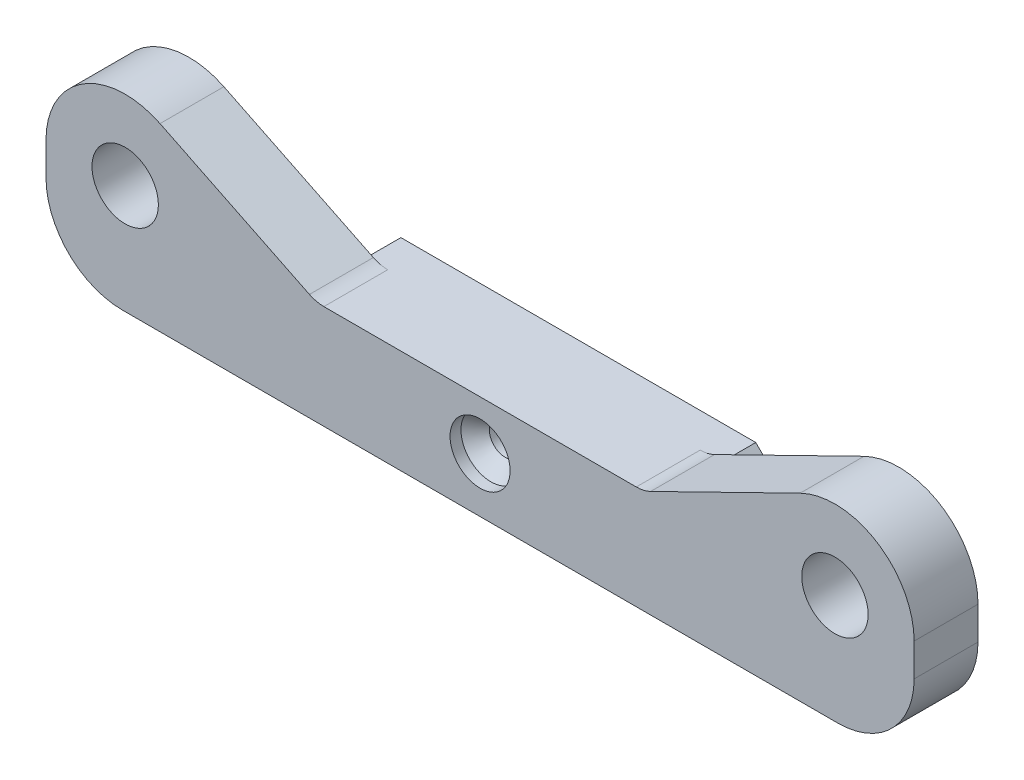
from build123d import *

# Parameters (mm, degrees)
SKETCH1_W                    = 77.5
SKETCH1_H                    = 7
BOSS_EXTRUDE1_DEPTH          = 9
BOSS_EXTRUDE1_DEPTH_BACK     = 9
SKETCH2_W                    = 20
SKETCH2_H                    = 6.3
CUT_EXTRUDE1_DEPTH           = 8
SKETCH3_W                    = 12.5
SKETCH3_H                    = 5.85
BOSS_EXTRUDE2_DEPTH          = 8
SKETCH4_R                    = 3.04
CUT_EXTRUDE2_DEPTH           = 22
CUT_EXTRUDE2_DEPTH_BACK      = 24.5
CUT_EXTRUDE3_DEPTH           = 5
SKETCH6_R                    = 6.2
CUT_EXTRUDE4_DEPTH           = 1
MIRROR2_COPY_1_SKETCH_R      = 6.2
MIRROR2_COPY_1_DEPTH         = 1
SKETCH7_W                    = 12.5
SKETCH7_H                    = 8.5
CUT_EXTRUDE5_DEPTH           = 1
MIRROR5_COPY_1_SKETCH_W      = 12.5
MIRROR5_COPY_1_SKETCH_H      = 8.5
MIRROR5_COPY_1_DEPTH         = 1
TAP_DRILL_FOR_M2_TAP1_D      = 1.6
CUT_EXTRUDE6_DEPTH           = 27
SKETCH12_W                   = 83.830839912
SKETCH12_H                   = 36.587504352
CUT_EXTRUDE7_DEPTH           = 22
F_2_0_2_DIAMETER_HOLE1_D     = 2
F_2_0_2_DIAMETER_HOLE1_DEPTH = 30.5
F_2_0_2_DIAMETER_HOLE2_D     = 2
F_2_0_2_DIAMETER_HOLE2_DEPTH = 16
F_2_0_2_DIAMETER_HOLE2_TIP   = 0.600860619
ESQUISSE2_R                  = 3.04
BOSS_EXTRU_1_DEPTH           = 1
ESQUISSE5_R                  = 0.8
BOSS_EXTRU_3_DEPTH           = 5.85
ESQUISSE6_R                  = 0.8
BOSS_EXTRU_4_DEPTH           = 9
BOSS_EXTRUDE3_DEPTH          = 1.5
BOSS_EXTRUDE4_DEPTH          = 1
SKETCH28_R                   = 7.25
SKETCH28_R_2                 = 6.25
BOSS_EXTRUDE7_DEPTH          = 5.85
BOSS_EXTRUDE5_DEPTH          = 5.85
FILLET2_R                    = 3
CHAMFER1_SIZE                = 2.5
SKETCH27_R                   = 1
BOSS_EXTRUDE6_DEPTH          = 2
BOSS_EXTRUDE8_DEPTH          = 5.85
FILLET3_R                    = 7


with BuildPart() as part:
    # Sketch1 → Boss-Extrude1 (new body, two sides)
    with BuildSketch(Plane.XY) as boss_extrude1_sk:
        Rectangle(SKETCH1_W, SKETCH1_H)
    extrude(amount=BOSS_EXTRUDE1_DEPTH)
    extrude(boss_extrude1_sk.sketch, amount=-BOSS_EXTRUDE1_DEPTH_BACK)

    # Sketch2 → Cut-Extrude1 (cut, through all)
    with BuildSketch(Plane(origin=(0, 3.5, 0), x_dir=(1, 0, 0), z_dir=(0, 1, 0))):
        with Locations((-28.75, 0)):
            Rectangle(SKETCH2_W, SKETCH2_H)
        with Locations((28.75, 0)):
            Rectangle(SKETCH2_W, SKETCH2_H)
    extrude(amount=-CUT_EXTRUDE1_DEPTH, mode=Mode.SUBTRACT)

    # Sketch3 → Boss-Extrude2 (add)
    with BuildSketch(Plane(origin=(0, 3.5, 0), x_dir=(1, 0, 0), z_dir=(0, 1, 0))):
        with Locations((-32.5, 6.075)):
            Rectangle(SKETCH3_W, SKETCH3_H)
        with Locations((-32.5, -6.075)):
            Rectangle(SKETCH3_W, SKETCH3_H)
        with Locations((32.5, -6.075)):
            Rectangle(SKETCH3_W, SKETCH3_H)
        with Locations((32.5, 6.075)):
            Rectangle(SKETCH3_W, SKETCH3_H)
    extrude(amount=BOSS_EXTRUDE2_DEPTH)

    # Sketch4 → Cut-Extrude2 (cut, two sides)
    with BuildSketch(Plane.XY) as cut_extrude2_sk:
        with Locations((-32.5, 5)):
            Circle(SKETCH4_R)
        with Locations((32.5, 5)):
            Circle(SKETCH4_R)
    extrude(amount=CUT_EXTRUDE2_DEPTH, mode=Mode.SUBTRACT)
    extrude(cut_extrude2_sk.sketch, amount=-CUT_EXTRUDE2_DEPTH_BACK, mode=Mode.SUBTRACT)

    # Sketch5 → Cut-Extrude3 (cut)
    with BuildSketch(Plane.XY):
        Polygon((15, 3.5), (36.256888292, -2.195766051), (36.256888292, 11.5), (15, 11.5), align=None)
    extrude(amount=-CUT_EXTRUDE3_DEPTH, mode=Mode.SUBTRACT)

    # Sketch6 → Cut-Extrude4 (cut)
    with BuildSketch(Plane.XY.offset(9)):
        with Locations((32.5, 5)):
            Circle(SKETCH6_R)
    cut_extrude4 = extrude(amount=-CUT_EXTRUDE4_DEPTH, mode=Mode.SUBTRACT)

    # Mirror1: Cut-Extrude4 across plane
    add(cut_extrude4.mirror(Plane.XY), mode=Mode.SUBTRACT)

    # Mirror2: Cut-Extrude4 across plane
    add(cut_extrude4.mirror(Plane(origin=(0, 0, 0), x_dir=(0, 0, 1), z_dir=(1, 0, 0))), mode=Mode.SUBTRACT)

    # Mirror2 copy 1 sketch → Mirror2 copy 1 (cut)
    with BuildSketch(Plane(origin=(0, 0, -9), x_dir=(-1, 0, 0), z_dir=(0, 0, -1))):
        with Locations((32.5, 5)):
            Circle(MIRROR2_COPY_1_SKETCH_R)
    extrude(amount=-MIRROR2_COPY_1_DEPTH, mode=Mode.SUBTRACT)

    # Sketch7 → Cut-Extrude5 (cut)
    with BuildSketch(Plane.XY.offset(9)):
        with Locations((-32.5, 7.25)):
            Rectangle(SKETCH7_W, SKETCH7_H)
    cut_extrude5 = extrude(amount=-CUT_EXTRUDE5_DEPTH, mode=Mode.SUBTRACT)

    # Mirror3: Cut-Extrude5 across plane
    add(cut_extrude5.mirror(Plane(origin=(0, 0, 0), x_dir=(0, 0, 1), z_dir=(1, 0, 0))), mode=Mode.SUBTRACT)

    # Mirror5: Cut-Extrude5 across plane
    add(cut_extrude5.mirror(Plane.XY), mode=Mode.SUBTRACT)

    # Mirror5 copy 1 sketch → Mirror5 copy 1 (cut)
    with BuildSketch(Plane(origin=(0, 0, -9), x_dir=(-1, 0, 0), z_dir=(0, 0, -1))):
        with Locations((-32.5, 7.25)):
            Rectangle(MIRROR5_COPY_1_SKETCH_W, MIRROR5_COPY_1_SKETCH_H)
    extrude(amount=-MIRROR5_COPY_1_DEPTH, mode=Mode.SUBTRACT)

    # Tap Drill for M2 Tap1 (through all)
    with Locations(Plane.XY.offset(9)):
        with Locations((-25, 0), (0, 0), (25, 0)):
            Hole(TAP_DRILL_FOR_M2_TAP1_D / 2)

    # Sketch11 → Cut-Extrude6 (cut)
    with BuildSketch(Plane.XY.offset(9)):
        with BuildLine():
            Line((-38.75, 4.999999534), (-38.75, 21.221242017))
            Line((-38.75, 21.221242017), (-26.25, 21.221242017))
            Line((-26.25, 21.221242017), (-26.25, 4.999999534))
            ThreePointArc((-26.25, 4.999999534), (-32.5, 11.25), (-38.75, 4.999999534))
        make_face()
    cut_extrude6 = extrude(amount=-CUT_EXTRUDE6_DEPTH, mode=Mode.SUBTRACT)

    # Mirror6: Cut-Extrude6 across plane
    add(cut_extrude6.mirror(Plane(origin=(0, 0, 0), x_dir=(0, 0, 1), z_dir=(1, 0, 0))), mode=Mode.SUBTRACT)

    # Sketch12 → Cut-Extrude7 (cut)
    with BuildSketch(Plane.XY):
        Rectangle(SKETCH12_W, SKETCH12_H)
    extrude(amount=-CUT_EXTRUDE7_DEPTH, mode=Mode.SUBTRACT)

    # 2.0 _2_ Diameter Hole1
    with Locations(Plane.XY.offset(9)):
        with Locations((-15, 0)):
            Hole(F_2_0_2_DIAMETER_HOLE1_D / 2, depth=F_2_0_2_DIAMETER_HOLE1_DEPTH)

    # 2.0 _2_ Diameter Hole2
    with Locations(Plane.XY.offset(9)):
        with Locations((15, 0)):
            Hole(F_2_0_2_DIAMETER_HOLE2_D / 2, depth=F_2_0_2_DIAMETER_HOLE2_DEPTH)
            with Locations((0, 0, -(F_2_0_2_DIAMETER_HOLE2_DEPTH + F_2_0_2_DIAMETER_HOLE2_TIP / 2))):  # 118° drill point
                Cone(0, F_2_0_2_DIAMETER_HOLE2_D / 2, F_2_0_2_DIAMETER_HOLE2_TIP, mode=Mode.SUBTRACT)

    # Esquisse2 → Boss.-Extru.1 (add)
    with BuildSketch(Plane.XY.offset(8)):
        with BuildLine():
            ThreePointArc((26.6314397, 3), (31.48636147, 11.116578858), (38.7, 5))
            ThreePointArc((38.7, 5), (38.616578858, 3.98636147), (38.3685603, 3))
            Line((38.3685603, 3), (38.75, 3))
            Line((38.75, 3), (38.75, 4.999999534))
            ThreePointArc((38.75, 4.999999534), (32.5, 11.25), (26.25, 4.999999534))
            Line((26.25, 4.999999534), (26.25, 3.5))
            Line((26.25, 3.5), (26.25, 3))
            Line((26.25, 3), (26.6314397, 3))
        make_face()
        with BuildLine():
            ThreePointArc((38.3685603, 3), (38.616578858, 3.98636147), (38.7, 5))
            ThreePointArc((38.7, 5), (31.48636147, 11.116578858), (26.6314397, 3))
            ThreePointArc((26.6314397, 3), (32.5, -1.2), (38.3685603, 3))
        make_face()
        with Locations((32.5, 5)):
            Circle(ESQUISSE2_R, mode=Mode.SUBTRACT)
    boss_extru_1 = extrude(amount=BOSS_EXTRU_1_DEPTH)

    # Sym_trie1: Boss.-Extru.1 across plane
    add(boss_extru_1.mirror(Plane(origin=(0, 0, 0), x_dir=(0, 0, 1), z_dir=(1, 0, 0))))

    # Esquisse5 → Boss.-Extru.3 (add)
    with BuildSketch(Plane.XY.offset(9)):
        with Locations((-25, 0)):
            Circle(ESQUISSE5_R)
        with Locations((25, 0)):
            Circle(ESQUISSE5_R)
    extrude(amount=-BOSS_EXTRU_3_DEPTH)

    # Esquisse6 → Boss.-Extru.4 (add)
    with BuildSketch(Plane.XY.offset(9)):
        Circle(ESQUISSE6_R)
    extrude(amount=-BOSS_EXTRU_4_DEPTH)

    # Sketch22 → Boss-Extrude3 (add)
    with BuildSketch(Plane.XZ.offset(3.5)):
        Polygon((-18.75, 0), (18.75, 0), (18.75, 3.15), (38.75, 3.15), (38.75, 9), (-38.75, 9), (-38.75, 3.15), (-18.75, 3.15), align=None)
    extrude(amount=BOSS_EXTRUDE3_DEPTH)

    # Sketch23 → CSK for M2.5 Countersunk Flat Head Screw (revolve, cut)
    with BuildSketch(Plane(origin=(0, 0, 9), x_dir=(0, -1, 0), z_dir=(1, 0, 0))):
        Polygon((0, 0), (0, 9), (1.45, 9), (1.45, 2.3), (2.75, 1), (2.75, 0), align=None)
    revolve(axis=Axis((0, 0, 15.35), (0, 0, -1)), mode=Mode.SUBTRACT)

    # Sketch25 → Boss-Extrude4 (add)
    with BuildSketch(Plane(origin=(0, 3.5, 0), x_dir=(1, 0, 0), z_dir=(0, 1, 0))):
        Polygon((18.75, 0), (-18.75, 0), (-18.75, -3.15), (-26.25, -3.15), (-26.25, -9), (26.25, -9), (26.25, -3.15), (18.75, -3.15), align=None)
    extrude(amount=BOSS_EXTRUDE4_DEPTH)

    # Sketch28 → Boss-Extrude7 (add)
    with BuildSketch(Plane.XY.offset(9)):
        with Locations((-32.5, 5)):
            Circle(SKETCH28_R)
        with Locations((-32.5, 5)):
            Circle(SKETCH28_R_2, mode=Mode.SUBTRACT)
        with Locations((32.5, 5)):
            Circle(SKETCH28_R)
        with Locations((32.5, 5)):
            Circle(SKETCH28_R_2, mode=Mode.SUBTRACT)
    extrude(amount=-BOSS_EXTRUDE7_DEPTH)

    # Sketch26 → Boss-Extrude5 (add)
    with BuildSketch(Plane(origin=(0, 0, 3.15), x_dir=(-1, 0, 0), z_dir=(0, 0, -1))):
        Polygon((-29.310409021, 11.510684249), (-15, 4.5), (-25.267261929, 4.5), align=None)
        Polygon((25.267261929, 4.5), (29.310409021, 11.510684249), (15, 4.5), align=None)
    extrude(amount=-BOSS_EXTRUDE5_DEPTH)

    # Fillet2
    fillet2_edges = [part.edges().sort_by_distance(p)[0] for p in [
        (15, 4.5, 6.075),
        (-15, 4.5, 6.075),
    ]]
    fillet(fillet2_edges, radius=FILLET2_R)

    # Chamfer1
    chamfer1_edges = [part.edges().sort_by_distance(p)[0] for p in [
        (-18.75, -5, 1.575),
        (18.75, -5, 1.575),
        (18.75, 4.5, 1.575),
        (-18.75, 4.5, 1.575),
    ]]
    chamfer(chamfer1_edges, length=CHAMFER1_SIZE)

    # Sketch27 → Boss-Extrude6 (add)
    with BuildSketch(Plane.XY.offset(9)):
        with Locations((-15, 0)):
            Circle(SKETCH27_R)
        with Locations((15, 0)):
            Circle(SKETCH27_R)
    extrude(amount=-BOSS_EXTRUDE6_DEPTH)

    # Sketch29 → Boss-Extrude8 (add)
    with BuildSketch(Plane(origin=(0, 0, 3.15), x_dir=(-1, 0, 0), z_dir=(0, 0, -1))):
        Polygon((-39.75, 5), (-39.75, -5), (-38.75, -5), (-38.75, 1.325765386), align=None)
        Polygon((38.75, 1.325765386), (39.75, 5), (39.75, -5), (38.75, -5), align=None)
    extrude(amount=-BOSS_EXTRUDE8_DEPTH)

    # Fillet3
    fillet3_edges = [part.edges().sort_by_distance(p)[0] for p in [
        (39.75, -5, 6.075),
        (-39.75, -5, 6.075),
    ]]
    fillet(fillet3_edges, radius=FILLET3_R)


solid = part.part
